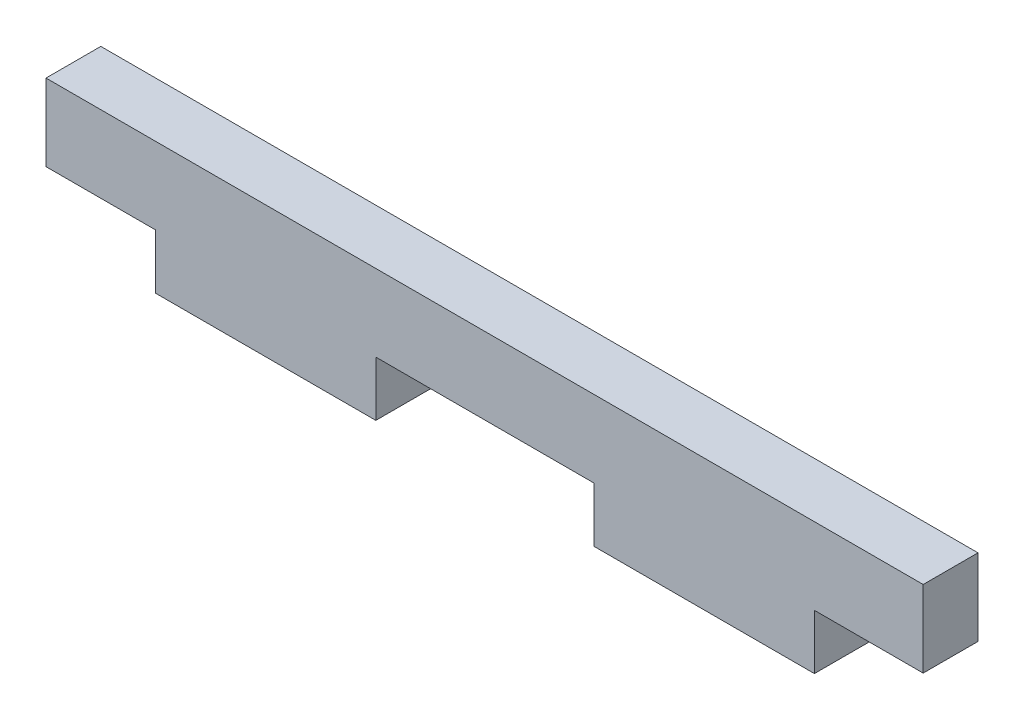
from build123d import *

# Parameters (mm, degrees)
BOSS_EXTRUDE1_DEPTH = 1.5875


with BuildPart() as part:
    # Sketch1 → Boss-Extrude1 (new body, symmetric)
    with BuildSketch(Plane.XY):
        Polygon((-6.2992, -2.2225), (6.35, -2.2225), (6.35, -5.3975), (19.1008, -5.3975), (19.1008, -2.2225), (25.4, -2.2225), (25.4, 2.2225), (-25.4, 2.2225), (-25.4, -2.2225), (-19.05, -2.2225), (-19.05, -5.3975), (-6.2992, -5.3975), align=None)
    extrude(amount=BOSS_EXTRUDE1_DEPTH, both=True)


solid = part.part
